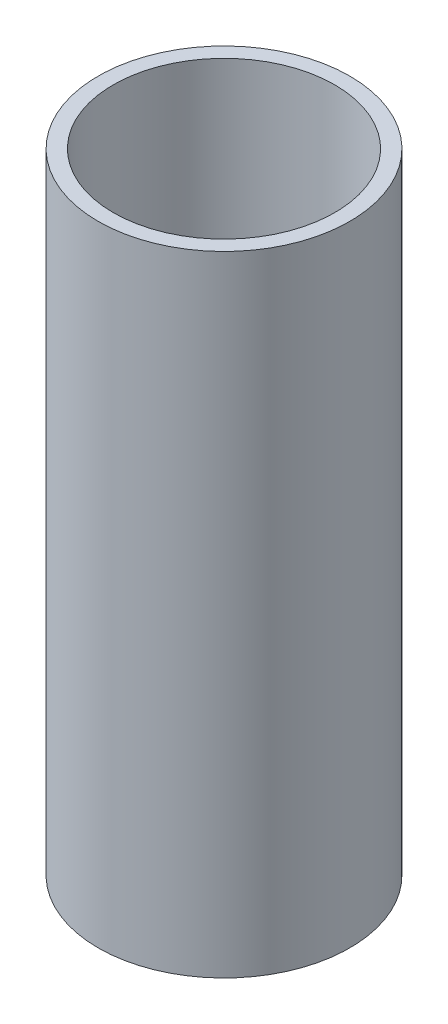
from build123d import *

# Parameters (mm, degrees)
SKETCH_1_R      = 25
SKETCH_1_R_2    = 22
EXTRUDE_1_DEPTH = 125


with BuildPart() as part:
    # 草圖1 → 填料-伸長1 (new body)
    with BuildSketch(Plane(origin=(0, 0, 0), x_dir=(1, 0, 0), z_dir=(0, 1, 0))):
        Circle(SKETCH_1_R)
        Circle(SKETCH_1_R_2, mode=Mode.SUBTRACT)
    extrude(amount=EXTRUDE_1_DEPTH)


solid = part.part
